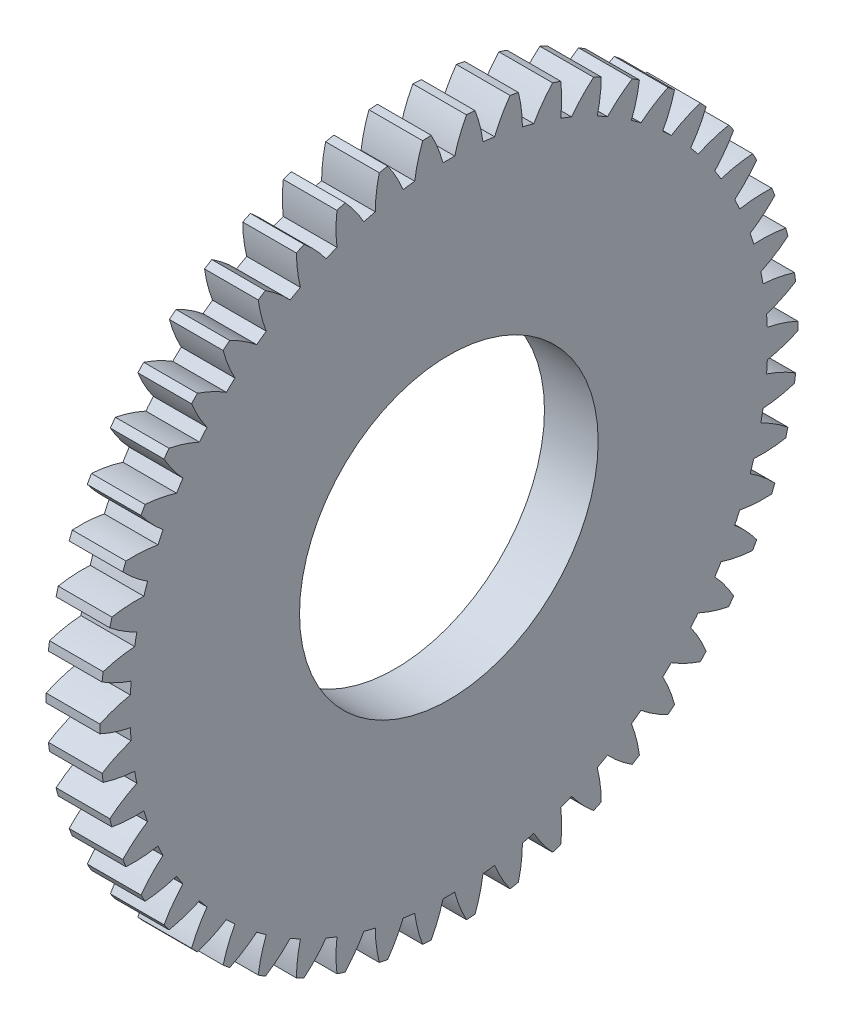
from build123d import *

# Parameters (mm, degrees)
BASPROSKE_W        = 4
BASPROSKE_H        = 26
TOOTHCUT_DEPTH     = 37.986484018
TEETHCUTS_COUNT    = 50
TEETHCUTS_ANGLE    = 352.8
BORSKE_R           = 2.5
BORE_DEPTH         = 50.0000508
CUT_EXTRUDE1_REACH = 38.963
SKETCH1_R          = 11.125


with BuildPart() as part:
    # BasProSke → Base-Revolve (revolve)
    with BuildSketch(Plane(origin=(0, 0, 0), x_dir=(1, 0, 0), z_dir=(0, 1, 0)), mode=Mode.PRIVATE) as base_revolve_sk:
        with Locations((2, 13)):
            Rectangle(BASPROSKE_W, BASPROSKE_H)
    revolve(base_revolve_sk.sketch.rotate(Axis((-10, 0, 0), (1, 0, 0)), 180), axis=Axis((-10, 0, 0), (1, 0, 0)))

    # TooCutSke → ToothCut (cut, through all)
    with BuildSketch(Plane(origin=(0, 0, 0), x_dir=(0, 0, -1), z_dir=(1, 0, 0))):
        with BuildLine():
            ThreePointArc((0.437663408, 23.744966872), (0, 23.749), (-0.437663408, 23.744966872))
            ThreePointArc((-0.437663408, 23.744966872), (-0.815428123, 24.895236298), (-1.329433358, 25.991422664))
            ThreePointArc((-1.329433358, 25.991422664), (0, 26.0254), (1.329433358, 25.991422664))
            ThreePointArc((1.329433358, 25.991422664), (0.815428123, 24.895236298), (0.437663408, 23.744966872))
        make_face()
    toothcut = extrude(amount=TOOTHCUT_DEPTH, mode=Mode.SUBTRACT)

    # TeethCuts: ToothCut ×50 about axis
    teethcuts_axis = Axis((-10, 0, 0), (1, 0, 0))
    for i in range(1, TEETHCUTS_COUNT):
        add(toothcut.rotate(teethcuts_axis, i * TEETHCUTS_ANGLE / (TEETHCUTS_COUNT - 1)), mode=Mode.SUBTRACT)

    # BorSke → Bore (cut, symmetric)
    with BuildSketch(Plane(origin=(0, 0, 0), x_dir=(0, 0, -1), z_dir=(1, 0, 0))):
        with Locations(Location((0, 0, 0), (0, 0, 180))):
            Circle(BORSKE_R)
    extrude(amount=BORE_DEPTH, both=True, mode=Mode.SUBTRACT)

    # Sketch1 → Cut-Extrude1 (cut, up to next)
    with BuildSketch(Plane.ZY, mode=Mode.PRIVATE) as cut_extrude1_sk1:
        Circle(SKETCH1_R)
    cut_extrude1_tool1 = extrude(cut_extrude1_sk1.sketch, amount=-CUT_EXTRUDE1_REACH, mode=Mode.PRIVATE) & part.part
    add(cut_extrude1_tool1.solids().sort_by_distance((0, 0, 0))[0], mode=Mode.SUBTRACT)


solid = part.part
